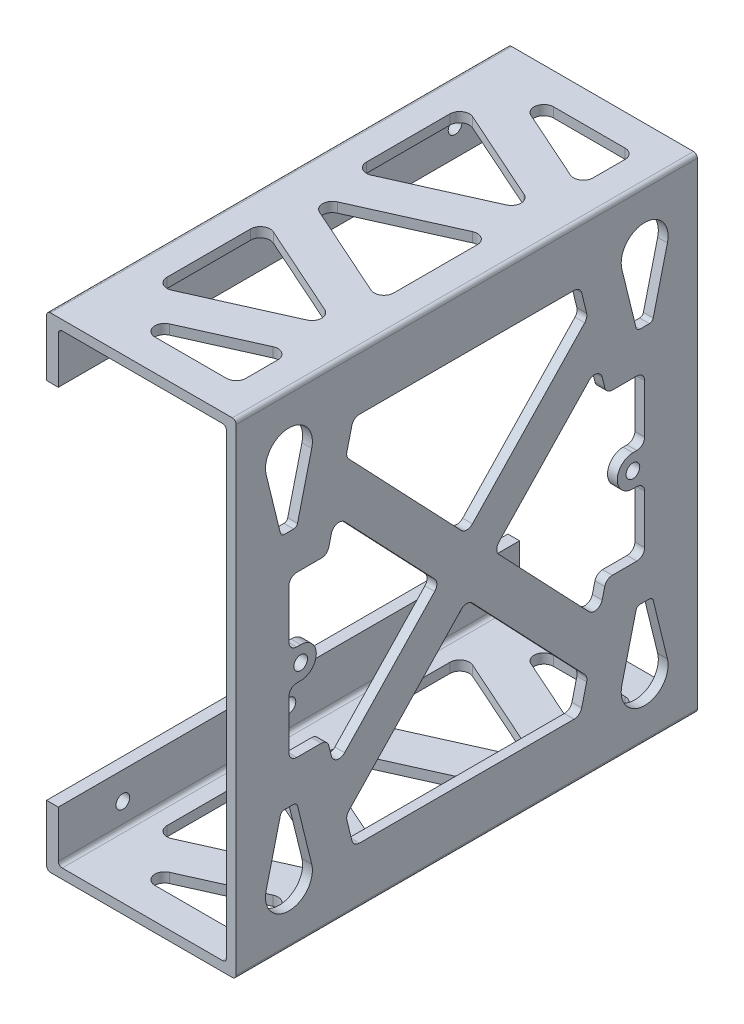
from build123d import *

# Parameters (mm, degrees)
EXTRUDE_1_DEPTH                          = 118
CUT_EXTRUDE_1_DEPTH                      = 2.5
SKETCH_3_R                               = 1.75
CUT_EXTRUDE_2_DEPTH                      = 3
MIRROR2_AT_THE_SECOND_PLANE_COPY_1_DEPTH = 2.5
FILLET1_R                                = 1
CUT_EXTRUDE_3_DEPTH                      = 2.5
MIRROR3_AT_THE_SECOND_PLANE_COPY_1_DEPTH = 2.5
FILLET2_R                                = 2
SKETCH1_R                                = 1.75
BOSS_EXTRUDE1_DEPTH                      = 2.5
FILLET3_R                                = 2
CUT_EXTRUDE_4_DEPTH                      = 124
FILLET_3_R                               = 2.5
FILLET_2_R                               = 1


with BuildPart() as part:
    # Sketch 1 → Extrude 1 (new body)
    with BuildSketch(Plane.XY):
        Polygon((0, 15.5), (0, 0), (48.5, 0), (48.5, 124), (0, 124), (0, 108.5), (3, 108.5), (3, 121.5), (46, 121.5), (46, 2.5), (3, 2.5), (3, 15.5), align=None)
    extrude(amount=-EXTRUDE_1_DEPTH)

    # Sketch 2 → Cut-Extrude 1 (cut)
    with BuildSketch(Plane.ZY.offset(-46)):
        with BuildLine():
            Line((-15.5, 92.5), (-11.5, 92.5))
            Line((-11.5, 92.5), (-7.673432105, 108.067831517))
            ThreePointArc((-7.673432105, 108.067831517), (-13.5, 115.5), (-19.326567895, 108.067831517))
            Line((-19.326567895, 108.067831517), (-15.5, 92.5))
        make_face()
    cut_extrude_1 = extrude(amount=-CUT_EXTRUDE_1_DEPTH, mode=Mode.SUBTRACT)

    # Sketch 3 → Cut-Extrude 2 (cut)
    with BuildSketch(Plane.ZY):
        with Locations((-101.5, 115.5)):
            Circle(SKETCH_3_R)
        with Locations((-59, 115.5)):
            Circle(SKETCH_3_R)
        with Locations((-16.5, 115.5)):
            Circle(SKETCH_3_R)
        with Locations((-16.5, 8.5)):
            Circle(SKETCH_3_R)
        with Locations((-59, 8.5)):
            Circle(SKETCH_3_R)
        with Locations((-101.5, 8.5)):
            Circle(SKETCH_3_R)
    extrude(amount=-CUT_EXTRUDE_2_DEPTH, mode=Mode.SUBTRACT)

    # Mirror2: Cut-Extrude 1 across plane
    add(cut_extrude_1.mirror(Plane.ZX.offset(62)), mode=Mode.SUBTRACT)

    # Mirror2 at the second plane: Cut-Extrude 1 across plane
    add(cut_extrude_1.mirror(Plane.XY.offset(-59)), mode=Mode.SUBTRACT)

    # Mirror2 at the second plane copy 1 sketc → Mirror2 at the second plane copy 1 (cut)
    with BuildSketch(Plane(origin=(46, 124, -118), x_dir=(0, 0, -1), z_dir=(-1, 0, 0))):
        with BuildLine():
            Line((-15.5, 92.5), (-11.5, 92.5))
            Line((-11.5, 92.5), (-7.673432105, 108.067831517))
            ThreePointArc((-7.673432105, 108.067831517), (-13.5, 115.5), (-19.326567895, 108.067831517))
            Line((-19.326567895, 108.067831517), (-15.5, 92.5))
        make_face()
    extrude(amount=-MIRROR2_AT_THE_SECOND_PLANE_COPY_1_DEPTH, mode=Mode.SUBTRACT)

    # Fillet1
    fillet1_edges = [part.edges().sort_by_distance(p)[0] for p in [
        (47.25, 31.5, -106.5),
        (47.25, 31.5, -102.5),
        (47.25, 92.5, -11.5),
        (47.25, 92.5, -15.5),
        (47.25, 92.5, -106.5),
        (47.25, 92.5, -102.5),
        (47.25, 31.5, -11.5),
        (47.25, 31.5, -15.5),
    ]]
    fillet(fillet1_edges, radius=FILLET1_R)

    # Sketch 4 → Cut-Extrude 3 (cut)
    with BuildSketch(Plane.ZY.offset(-46)):
        Polygon((-28.072165863, 101.753504842), (-59, 69.25306897), (-59, 109.5), (-29.976251839, 109.5), align=None)
        Polygon((-52.09788598, 62), (-13.5, 62), (-13.5, 82.5), (-23.33966067, 82.5), (-25.238493657, 90.225124137), align=None)
    cut_extrude_3 = extrude(amount=-CUT_EXTRUDE_3_DEPTH, mode=Mode.SUBTRACT)

    # Mirror3: Cut-Extrude 3 across plane
    add(cut_extrude_3.mirror(Plane.XY.offset(-59)), mode=Mode.SUBTRACT)

    # Mirror3 at the second plane: Cut-Extrude 3 across plane
    add(cut_extrude_3.mirror(Plane.ZX.offset(62)), mode=Mode.SUBTRACT)

    # Mirror3 at the second plane copy 1 sketc → Mirror3 at the second plane copy 1 (cut)
    with BuildSketch(Plane(origin=(46, 124, -118), x_dir=(0, 0, -1), z_dir=(-1, 0, 0))):
        Polygon((-28.072165863, 101.753504842), (-59, 69.25306897), (-59, 109.5), (-29.976251839, 109.5), align=None)
        Polygon((-52.09788598, 62), (-13.5, 62), (-13.5, 82.5), (-23.33966067, 82.5), (-25.238493657, 90.225124137), align=None)
    extrude(amount=-MIRROR3_AT_THE_SECOND_PLANE_COPY_1_DEPTH, mode=Mode.SUBTRACT)

    # Fillet2
    fillet2_edges = [part.edges().sort_by_distance(p)[0] for p in [
        (47.25, 109.5, -29.976251839),
        (47.25, 101.753504842, -28.072165863),
        (47.25, 69.25306897, -59),
        (47.25, 90.225124137, -25.238493657),
        (47.25, 82.5, -23.33966067),
        (47.25, 82.5, -13.5),
        (47.25, 62, -52.09788598),
        (47.25, 22.246495158, -28.072165863),
        (47.25, 14.5, -29.976251839),
        (47.25, 54.74693103, -59),
        (47.25, 41.5, -23.33966067),
        (47.25, 33.774875863, -25.238493657),
        (47.25, 41.5, -13.5),
        (47.25, 101.753504842, -89.927834137),
        (47.25, 109.5, -88.023748161),
        (47.25, 82.5, -94.66033933),
        (47.25, 90.225124137, -92.761506343),
        (47.25, 62, -65.90211402),
        (47.25, 82.5, -104.5),
        (47.25, 14.5, -88.023748161),
        (47.25, 22.246495158, -89.927834137),
        (47.25, 33.774875863, -92.761506343),
        (47.25, 41.5, -94.66033933),
        (47.25, 41.5, -104.5),
    ]]
    fillet(fillet2_edges, radius=FILLET2_R)

    # Sketch1 → Boss-Extrude1 (add)
    with BuildSketch(Plane(origin=(48.5, 0, 0), x_dir=(0, 0, -1), z_dir=(1, 0, 0))):
        with BuildLine():
            Line((101.5, 66), (104.5, 66))
            Line((104.5, 66), (104.5, 58))
            Line((104.5, 58), (101.5, 58))
            ThreePointArc((101.5, 58), (97.5, 62), (101.5, 66))
        make_face()
        with Locations((101.5, 62)):
            Circle(SKETCH1_R, mode=Mode.SUBTRACT)
        with BuildLine():
            Line((16.5, 66), (13.5, 66))
            Line((13.5, 66), (13.5, 58))
            Line((13.5, 58), (16.5, 58))
            ThreePointArc((16.5, 58), (20.5, 62), (16.5, 66))
        make_face()
        with Locations((16.5, 62)):
            Circle(SKETCH1_R, mode=Mode.SUBTRACT)
    extrude(amount=-BOSS_EXTRUDE1_DEPTH)

    # Fillet3
    fillet3_edges = [part.edges().sort_by_distance(p)[0] for p in [
        (47.25, 58, -13.5),
        (47.25, 66, -13.5),
        (47.25, 66, -104.5),
        (47.25, 58, -104.5),
    ]]
    fillet(fillet3_edges, radius=FILLET3_R)

    # Sketch 5 → Cut-Extrude 4 (cut)
    with BuildSketch(Plane.XZ):
        Polygon((40.5, -8), (8, -8), (40.5, -22.544309035), align=None)
        Polygon((8, -18.955690965), (40.5, -33.5), (8, -48.044309035), align=None)
        Polygon((40.5, -44.455690965), (8, -59), (40.5, -73.544309035), align=None)
        Polygon((40.5, -84.5), (8, -69.955690965), (8, -99.044309035), align=None)
        Polygon((8, -110), (40.5, -95.455690965), (40.5, -110), align=None)
    extrude(amount=-CUT_EXTRUDE_4_DEPTH, mode=Mode.SUBTRACT)

    # Fillet 3
    fillet_3_edges = [part.edges().sort_by_distance(p)[0] for p in [
        (40.5, 1.25, -110),
        (8, 1.25, -110),
        (40.5, 1.25, -95.455690965),
        (40.5, 122.75, -110),
        (8, 122.75, -110),
        (40.5, 122.75, -95.455690965),
        (8, 1.25, -48.044309035),
        (8, 1.25, -18.955690965),
        (40.5, 1.25, -33.5),
        (8, 122.75, -48.044309035),
        (8, 122.75, -18.955690965),
        (40.5, 122.75, -33.5),
        (40.5, 1.25, -84.5),
        (8, 1.25, -99.044309035),
        (8, 1.25, -69.955690965),
        (40.5, 122.75, -84.5),
        (8, 122.75, -99.044309035),
        (8, 122.75, -69.955690965),
        (40.5, 1.25, -44.455690965),
        (40.5, 1.25, -73.544309035),
        (8, 1.25, -59),
        (40.5, 122.75, -44.455690965),
        (40.5, 122.75, -73.544309035),
        (8, 122.75, -59),
        (40.5, 1.25, -22.544309035),
        (8, 1.25, -8),
        (40.5, 1.25, -8),
        (40.5, 122.75, -22.544309035),
        (8, 122.75, -8),
        (40.5, 122.75, -8),
    ]]
    fillet(fillet_3_edges, radius=FILLET_3_R)

    # Fillet 2
    fillet_2_edges = [part.edges().sort_by_distance(p)[0] for p in [
        (3, 2.5, -59),
        (46, 2.5, -59),
        (46, 121.5, -59),
        (3, 121.5, -59),
        (0, 124, -59),
        (48.5, 124, -59),
        (48.5, 0, -59),
        (0, 0, -59),
    ]]
    fillet(fillet_2_edges, radius=FILLET_2_R)


solid = part.part
